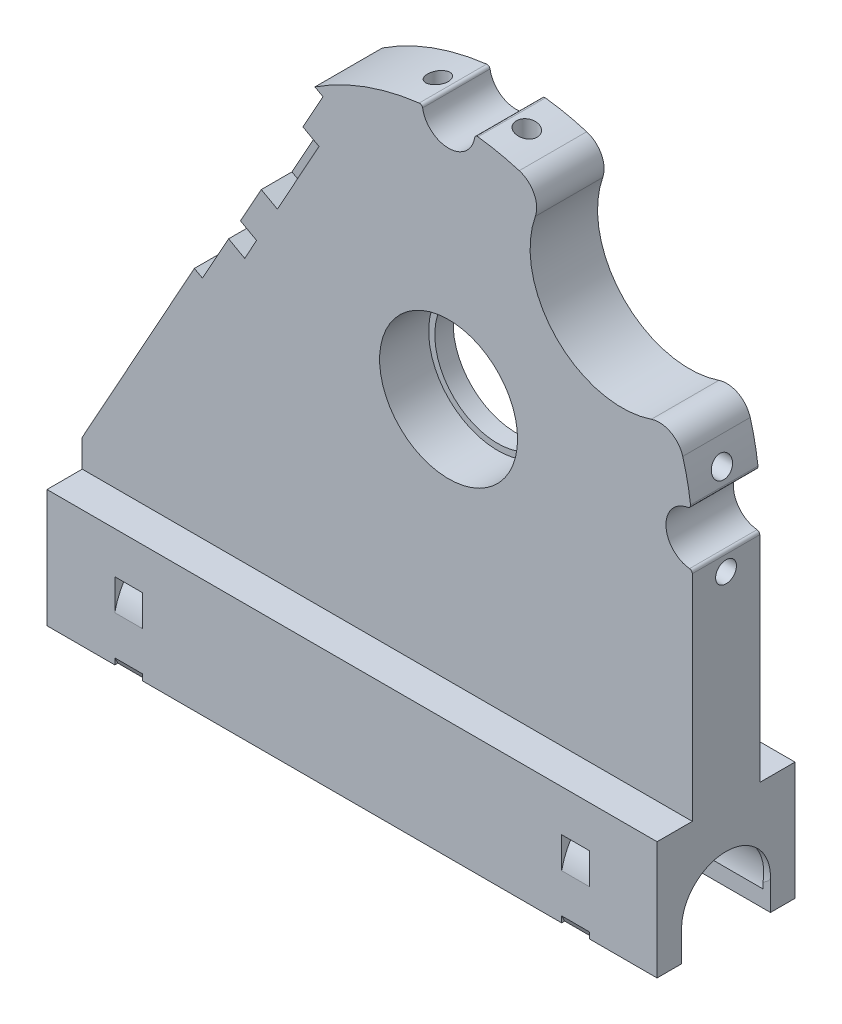
from build123d import *

# Parameters (mm, degrees)
CROQUIS1_W                           = 2.85
CROQUIS1_H                           = 6.25
CROQUIS1_R                           = 11.25
CROQUIS1_W_2                         = 6.25
CROQUIS1_H_2                         = 2.85
CROQUIS1_R_2                         = 10.25
SALIENTE_EXTRUIR1_DEPTH              = 11
CROQUIS1_8_R                         = 11.25
CORTAR_EXTRUIR1_DEPTH                = 8
CORTAR_EXTRUIR2_DEPTH                = 5
CROQUIS3_R                           = 1.7
CORTAR_EXTRUIR3_DEPTH                = 121.735059853
CORTAR_EXTRUIR3_DEPTH_BACK           = 10.95
CROQUIS5_R                           = 1.7
CORTAR_EXTRUIR4_DEPTH                = 87.935931019
CORTAR_EXTRUIR4_DEPTH_BACK           = 10
SALIENTE_EXTRUIR8_DEPTH              = 2.85
SALIENTE_EXTRUIR9_DEPTH              = 2.85
SALIENTE_EXTRUIR10_REACH             = 96.185
SALIENTE_EXTRUIR10_DIRECTION_2_REACH = 96.185
CORTAR_EXTRUIR5_DEPTH                = 2.25
CROQUIS15_W                          = 32
CROQUIS15_H                          = 19.25
SALIENTE_EXTRUIR11_DEPTH             = 18.6
CORTAR_EXTRUIR6_DEPTH                = 107.943336294
CORTAR_EXTRUIR6_DEPTH_BACK           = 107.943336294
SALIENTE_EXTRUIR12_DEPTH             = 2.9
CORTAR_EXTRUIR9_DEPTH                = 2.2
CROQUIS18_R                          = 15
CORTAR_EXTRUIR10_DEPTH               = 100.997185849
REDONDEO1_R                          = 4
CORTAR_EXTRUIR11_DEPTH               = 9
CROQUIS19_R                          = 1.7
CORTAR_EXTRUIR12_DEPTH               = 17
CORTAR_EXTRUIR13_DEPTH               = 2.8


with BuildPart() as part:
    # Croquis1 → Saliente-Extruir1 (new body)
    with BuildSketch(Plane.XY):
        Polygon((-13.758940625, 66.335591866), (-20.546275303, 54.090915976), (-17.922416234, 52.636487131), (-11.135081504, 64.881163005), align=None)
        Polygon((-23.939942645, 47.968578026), (-25.879547083, 44.469438992), (-23.255322093, 43.015670372), (-21.316083599, 46.514149194), align=None)
        with BuildLine():
            Line((-23.255322093, 43.015670372), (-25.879547083, 44.469438992))
            Line((-25.879547083, 44.469438992), (-30.145871741, 36.77278557))
            Line((-30.145871741, 36.77278557), (-31.457801302, 37.5))
            Line((-31.457801302, 37.5), (-49.75, 4.5))
            Line((-49.75, 4.5), (-49.75, 0))
            Line((-49.75, 0), (49.75, 0))
            Line((49.75, 0), (49.75, 34.976112695))
            ThreePointArc((49.75, 34.976112695), (49.621511552, 35.310745579), (49.302083333, 35.473392623))
            ThreePointArc((49.302083333, 35.473392623), (45.451952669, 39.620427093), (49.045277778, 43.99185886))
            ThreePointArc((49.045277778, 43.99185886), (49.363598896, 44.185452673), (49.459681529, 44.545417986))
            ThreePointArc((49.459681529, 44.545417986), (38.107494552, 67.857494552), (14.795417986, 79.209681529))
            ThreePointArc((14.795417986, 79.209681529), (14.435452673, 79.113598896), (14.24185886, 78.795277778))
            ThreePointArc((14.24185886, 78.795277778), (10.008940475, 75.200009294), (5.761108298, 78.77764473))
            ThreePointArc((5.761108298, 78.77764473), (5.567031298, 79.094534167), (5.207905747, 79.189999531))
            ThreePointArc((5.207905747, 79.189999531), (-3.654801562, 77.059839514), (-11.798771201, 72.965829125))
            Line((-11.798771201, 72.965829125), (-10.48684164, 72.238614694))
            Line((-10.48684164, 72.238614694), (-13.758940625, 66.335591866))
            Line((-13.758940625, 66.335591866), (-11.135081504, 64.881163005))
            Line((-11.135081504, 64.881163005), (-17.922416234, 52.636487131))
            Line((-17.922416234, 52.636487131), (-20.54627535, 54.090916001))
            Line((-20.546275303, 54.090915976), (-23.939942645, 47.968578026))
            Line((-23.939942715, 47.968578064), (-21.316083599, 46.514149194))
            Line((-21.316083599, 46.514149194), (-23.255322093, 43.015670372))
        make_face()
        with Locations((42.125, 32.5)):
            Rectangle(CROQUIS1_W, CROQUIS1_H, mode=Mode.SUBTRACT)
        with Locations((10, 39.75)):
            Circle(CROQUIS1_R, mode=Mode.SUBTRACT)
        with Locations((42.125, 47)):
            Rectangle(CROQUIS1_W, CROQUIS1_H, mode=Mode.SUBTRACT)
        with Locations((2.75, 71.865)):
            Rectangle(CROQUIS1_W_2, CROQUIS1_H_2, mode=Mode.SUBTRACT)
        with Locations((17.25, 71.865)):
            Rectangle(CROQUIS1_W_2, CROQUIS1_H_2, mode=Mode.SUBTRACT)
        with Locations((10, 39.75)):
            Circle(CROQUIS1_R)
        with Locations((10, 39.75)):
            Circle(CROQUIS1_R_2, mode=Mode.SUBTRACT)
    extrude(amount=-SALIENTE_EXTRUIR1_DEPTH)

    # Croquis1_8 → Cortar-Extruir1 (cut)
    with BuildSketch(Plane.XY):
        with Locations((10, 39.75)):
            Circle(CROQUIS1_8_R)
    extrude(amount=-CORTAR_EXTRUIR1_DEPTH, mode=Mode.SUBTRACT)

    # Croquis1_9 → Cortar-Extruir2 (cut)
    with BuildSketch(Plane.XY):
        Polygon((-13.758940625, 66.335591866), (-20.546275303, 54.090915976), (-17.922416234, 52.636487131), (-11.135081504, 64.881163005), align=None)
        Polygon((-23.939942645, 47.968578026), (-25.879547083, 44.469438992), (-23.255322093, 43.015670372), (-21.316083599, 46.514149194), align=None)
    extrude(amount=-CORTAR_EXTRUIR2_DEPTH, mode=Mode.SUBTRACT)

    # Croquis3 → Cortar-Extruir3 (cut, two sides)
    with BuildSketch(Plane(origin=(40.7, 0, 0), x_dir=(0, 0, -1), z_dir=(1, 0, 0))) as cortar_extruir3_sk:
        with Locations(Location((5.5, 47, 0), (0, 0, 90))):
            Circle(CROQUIS3_R)
        with Locations(Location((5.5, 32.5, 0), (0, 0, 90))):
            Circle(CROQUIS3_R)
    extrude(amount=CORTAR_EXTRUIR3_DEPTH, mode=Mode.SUBTRACT)
    extrude(cortar_extruir3_sk.sketch, amount=-CORTAR_EXTRUIR3_DEPTH_BACK, mode=Mode.SUBTRACT)

    # Croquis5 → Cortar-Extruir4 (cut, two sides)
    with BuildSketch(Plane(origin=(0, 70.44, 0), x_dir=(1, 0, 0), z_dir=(0, 1, 0))) as cortar_extruir4_sk:
        with Locations(Location((17.25, 5.5, 0), (0, 0, 270))):
            Circle(CROQUIS5_R)
        with Locations(Location((2.75, 5.5, 0), (0, 0, 270))):
            Circle(CROQUIS5_R)
    extrude(amount=CORTAR_EXTRUIR4_DEPTH, mode=Mode.SUBTRACT)
    extrude(cortar_extruir4_sk.sketch, amount=-CORTAR_EXTRUIR4_DEPTH_BACK, mode=Mode.SUBTRACT)

    # Croquis9 → Saliente-Extruir8 (add)
    with BuildSketch(Plane(origin=(0, 70.44, 0), x_dir=(1, 0, 0), z_dir=(0, 1, 0))):
        Polygon((17.25, 1.9), (14.132308546, 3.7), (14.125, 3.704219591), (14.125, 0), (20.375, 0), (20.375, 3.704219591), (20.367691454, 3.7), align=None)
        Polygon((2.75, 1.9), (-0.367691454, 3.7), (-0.375, 3.704219591), (-0.375, 0), (5.875, 0), (5.875, 3.704219591), (5.867691454, 3.7), align=None)
    extrude(amount=SALIENTE_EXTRUIR8_DEPTH)

    # Croquis11 → Saliente-Extruir9 (add)
    with BuildSketch(Plane(origin=(40.7, 0, 0), x_dir=(0, 0, -1), z_dir=(1, 0, 0))):
        Polygon((1.9, 32.5), (3.7, 35.617691454), (3.704219591, 35.625), (0, 35.625), (0, 29.375), (3.704219591, 29.375), (3.7, 29.382308546), align=None)
        Polygon((1.9, 47), (3.7, 50.117691454), (3.704219591, 50.125), (0, 50.125), (0, 43.875), (3.704219591, 43.875), (3.7, 43.882308546), align=None)
    extrude(amount=SALIENTE_EXTRUIR9_DEPTH)

    # Saliente-Extruir10: up to this face of the body (flat: up to its plane)
    saliente_extruir10_end = Plane(part.part.faces().sort_by_distance((-49.75, 2.25, -5.5))[0])
    # Croquis12 → Saliente-Extruir10 (add, up to the picked face)
    with BuildSketch(Plane(origin=(0, 0, 0), x_dir=(0, 0, -1), z_dir=(1, 0, 0)), mode=Mode.PRIVATE) as saliente_extruir10_sk1:
        with BuildLine():
            Line((-1.75, -19.25), (-5.75, -19.25))
            Line((-5.75, -19.25), (-5.75, 0))
            Line((-5.75, 0), (16.75, 0))
            Line((16.75, 0), (16.75, -19.25))
            Line((16.75, -19.25), (12.75, -19.25))
            Line((12.75, -19.25), (12.75, -14.25))
            ThreePointArc((12.75, -14.25), (5.5, -7), (-1.75, -14.25))
            Line((-1.75, -14.25), (-1.75, -19.25))
        make_face()
    saliente_extruir10_tool1 = split(extrude(saliente_extruir10_sk1.sketch, amount=-SALIENTE_EXTRUIR10_REACH, mode=Mode.PRIVATE), bisect_by=saliente_extruir10_end, keep=Keep.BOTH, mode=Mode.PRIVATE)
    add(saliente_extruir10_tool1.solids().sort_by(Axis((0, -16.75, 2.04611), (-1, 0, 0)))[0])

    # Saliente-Extruir10 direction 2: up to this face of the body (flat: up to its plane)
    saliente_extruir10_direction_2_end = Plane(part.part.faces().sort_by_distance((49.75, 17.125235731, -5.5))[0])
    # Croquis12 → Saliente-Extruir10 direction 2 (add, up to the picked face)
    with BuildSketch(Plane(origin=(0, 0, 0), x_dir=(0, 0, -1), z_dir=(1, 0, 0)), mode=Mode.PRIVATE) as saliente_extruir10_direction_2_sk1:
        with BuildLine():
            Line((-1.75, -19.25), (-5.75, -19.25))
            Line((-5.75, -19.25), (-5.75, 0))
            Line((-5.75, 0), (16.75, 0))
            Line((16.75, 0), (16.75, -19.25))
            Line((16.75, -19.25), (12.75, -19.25))
            Line((12.75, -19.25), (12.75, -14.25))
            ThreePointArc((12.75, -14.25), (5.5, -7), (-1.75, -14.25))
            Line((-1.75, -14.25), (-1.75, -19.25))
        make_face()
    saliente_extruir10_direction_2_tool1 = split(extrude(saliente_extruir10_direction_2_sk1.sketch, amount=SALIENTE_EXTRUIR10_DIRECTION_2_REACH, mode=Mode.PRIVATE), bisect_by=saliente_extruir10_direction_2_end, keep=Keep.BOTH, mode=Mode.PRIVATE)
    add(saliente_extruir10_direction_2_tool1.solids().sort_by(Axis((0, -16.75, 2.04611), (1, 0, 0)))[0])

    # Croquis13 → Cortar-Revolución1 (revolve, cut)
    with BuildSketch(Plane(origin=(0, -14.25, 0), x_dir=(1, 0, 0), z_dir=(0, 1, 0))):
        Polygon((-23.134002855, -1.75), (-23.134002855, 5.5), (-49.75, 5.5), (-49.75, -1.75), (-48.542001427, -1.863925069), (-48.542001427, -2.1), (-24.342001427, -2.1), (-24.342001427, -1.863925069), align=None)
    cortar_revoluci_n1 = revolve(axis=Axis((-23.134002855, -14.25, -5.5), (-1, 0, 0)), mode=Mode.SUBTRACT)

    # Simetría1: Cortar-Revolución1 across plane
    add(cortar_revoluci_n1.mirror(Plane(origin=(0, 0, 0), x_dir=(0, 0, 1), z_dir=(1, 0, 0))), mode=Mode.SUBTRACT)

    # Croquis14 → Cortar-Extruir5 (cut, symmetric)
    with BuildSketch(Plane(origin=(-36.442001427, 0, 0), x_dir=(0, 0, -1), z_dir=(1, 0, 0))):
        Polygon((16.75, -19.25), (16.25, -19.25), (16.75, -18.25), align=None)
        Polygon((-5.75, -18.25), (-5.25, -19.25), (-5.75, -19.25), align=None)
        with BuildLine():
            Line((16.75, -11.865151996), (16.75, -6.787594222))
            ThreePointArc((16.75, -6.787594222), (5.5, -0.75), (-5.75, -6.787594222))
            Line((-5.75, -6.787594222), (-5.75, -11.865151996))
            ThreePointArc((-5.75, -11.865151996), (5.5, -2.75), (16.75, -11.865151996))
        make_face()
    cortar_extruir5 = extrude(amount=CORTAR_EXTRUIR5_DEPTH, both=True, mode=Mode.SUBTRACT)

    # Simetría2: Cortar-Extruir5 across plane
    add(cortar_extruir5.mirror(Plane(origin=(0, 0, 0), x_dir=(0, 0, 1), z_dir=(1, 0, 0))), mode=Mode.SUBTRACT)

    # Croquis15 → Saliente-Extruir11 (add)
    with BuildSketch(Plane(origin=(0, 0, -16.75), x_dir=(-1, 0, 0), z_dir=(0, 0, -1))):
        with Locations((0, -9.625)):
            Rectangle(CROQUIS15_W, CROQUIS15_H)
    extrude(amount=SALIENTE_EXTRUIR11_DEPTH)

    # Croquis16 → Cortar-Extruir6 (cut, two sides)
    with BuildSketch(Plane.ZY.offset(12.8)) as cortar_extruir6_sk:
        with BuildLine():
            Line((-21.55, -3.0465), (-35.35, -3.0465))
            Line((-35.35, -3.0465), (-35.35, -5.125))
            Line((-35.35, -5.125), (-25.35, -5.125))
            ThreePointArc((-25.35, -5.125), (-20.85, -9.625), (-25.35, -14.125))
            Line((-25.35, -14.125), (-35.35, -14.125))
            Line((-35.35, -14.125), (-35.35, -16.207))
            Line((-35.35, -16.207), (-21.55047791, -16.207))
            Line((-21.55047791, -16.207), (-17.751368737, -9.62674989))
            Line((-17.751368737, -9.62674989), (-21.55, -3.0465))
        make_face()
        with BuildLine():
            Line((-25.35, -5.125), (-35.35, -5.125))
            Line((-35.35, -5.125), (-35.35, -14.125))
            Line((-35.35, -14.125), (-25.35, -14.125))
            ThreePointArc((-25.35, -14.125), (-20.85, -9.625), (-25.35, -5.125))
        make_face()
    extrude(amount=CORTAR_EXTRUIR6_DEPTH, mode=Mode.SUBTRACT)
    extrude(cortar_extruir6_sk.sketch, amount=-CORTAR_EXTRUIR6_DEPTH_BACK, mode=Mode.SUBTRACT)

    # Croquis16_3 → Saliente-Extruir12 (add)
    with BuildSketch(Plane.ZY.offset(12.8)):
        with BuildLine():
            Line((-21.55, -3.0465), (-35.35, -3.0465))
            Line((-35.35, -3.0465), (-35.35, -5.125))
            Line((-35.35, -5.125), (-25.35, -5.125))
            ThreePointArc((-25.35, -5.125), (-20.85, -9.625), (-25.35, -14.125))
            Line((-25.35, -14.125), (-35.35, -14.125))
            Line((-35.35, -14.125), (-35.35, -16.207))
            Line((-35.35, -16.207), (-21.55047791, -16.207))
            Line((-21.55047791, -16.207), (-17.751368737, -9.62674989))
            Line((-17.751368737, -9.62674989), (-21.55, -3.0465))
        make_face()
    extrude(amount=-SALIENTE_EXTRUIR12_DEPTH)

    # Croquis17 → Cortar-Extruir9 (cut)
    with BuildSketch(Plane(origin=(-9.9, 0, 0), x_dir=(0, 0, -1), z_dir=(1, 0, 0))):
        with BuildLine():
            Line((25.35, -1.425), (35.35, -1.425))
            Line((35.35, -1.425), (35.35, -5.125))
            Line((35.35, -5.125), (25.35, -5.125))
            ThreePointArc((25.35, -5.125), (20.85, -9.625), (25.35, -14.125))
            Line((25.35, -14.125), (35.35, -14.125))
            Line((35.35, -14.125), (35.35, -17.825))
            Line((35.35, -17.825), (25.35, -17.825))
            ThreePointArc((25.35, -17.825), (17.15, -9.625), (25.35, -1.425))
        make_face()
    extrude(amount=CORTAR_EXTRUIR9_DEPTH, mode=Mode.SUBTRACT)

    # Croquis18 → Cortar-Extruir10 (cut, through all)
    with BuildSketch(Plane.XY):
        with Locations((38.291977159, 67.671793073)):
            Circle(CROQUIS18_R)
    extrude(amount=-CORTAR_EXTRUIR10_DEPTH, mode=Mode.SUBTRACT)

    # Redondeo1
    redondeo1_edges = [part.edges().sort_by_distance(p)[0] for p in [
        (25.930319734, 76.168229133, -5.5),
        (46.624873152, 55.199309584, -5.5),
    ]]
    fillet(redondeo1_edges, radius=REDONDEO1_R)

    # Croquis1_10 → Cortar-Extruir11 (cut)
    with BuildSketch(Plane.XY):
        Polygon((-23.939942645, 47.968578026), (-25.879547083, 44.469438992), (-23.255322093, 43.015670372), (-21.316083599, 46.514149194), align=None)
    extrude(amount=-CORTAR_EXTRUIR11_DEPTH, mode=Mode.SUBTRACT)

    # Croquis19 → Cortar-Extruir12 (cut)
    with BuildSketch(Plane(origin=(-38.652920353, 21.425663617, 0), x_dir=(0, 0, 1), z_dir=(-0.874619707139392, 0.48480962024634405, 0))):
        with Locations(Location((-8, 35.347949162, 0), (0, 0, 270))):
            Circle(CROQUIS19_R)
        with Locations(Location((-8, 54.097949162, 0), (0, 0, 270))):
            Circle(CROQUIS19_R)
    extrude(amount=-CORTAR_EXTRUIR12_DEPTH, mode=Mode.SUBTRACT)

    # Croquis20 → Cortar-Extruir13 (cut)
    with BuildSketch(Plane(origin=(-33.929973935, 18.807691668, 0), x_dir=(0, 0, 1), z_dir=(-0.8746197071393919, 0.484809620246344, 0))):
        Polygon((-11, 55.965898355), (-8, 57.697949162), (-11, 57.697949162), align=None)
        Polygon((-4.882308546, 55.897949162), (-8, 57.697949162), (-11, 55.965898355), (-11, 52.22999997), (-8, 50.497949162), (-4.882308546, 52.297949162), align=None)
        Polygon((-8, 50.497949162), (-11, 52.22999997), (-11, 50.497949162), align=None)
        Polygon((-4.882308546, 37.147949162), (-8, 38.947949162), (-11, 37.215898355), (-11, 33.47999997), (-8, 31.747949162), (-4.882308546, 33.547949162), align=None)
        Polygon((-8, 38.947949162), (-11, 38.947949162), (-11, 37.215898355), align=None)
        Polygon((-8, 31.747949162), (-11, 33.47999997), (-11, 31.747949162), align=None)
    extrude(amount=CORTAR_EXTRUIR13_DEPTH, mode=Mode.SUBTRACT)


solid = part.part
